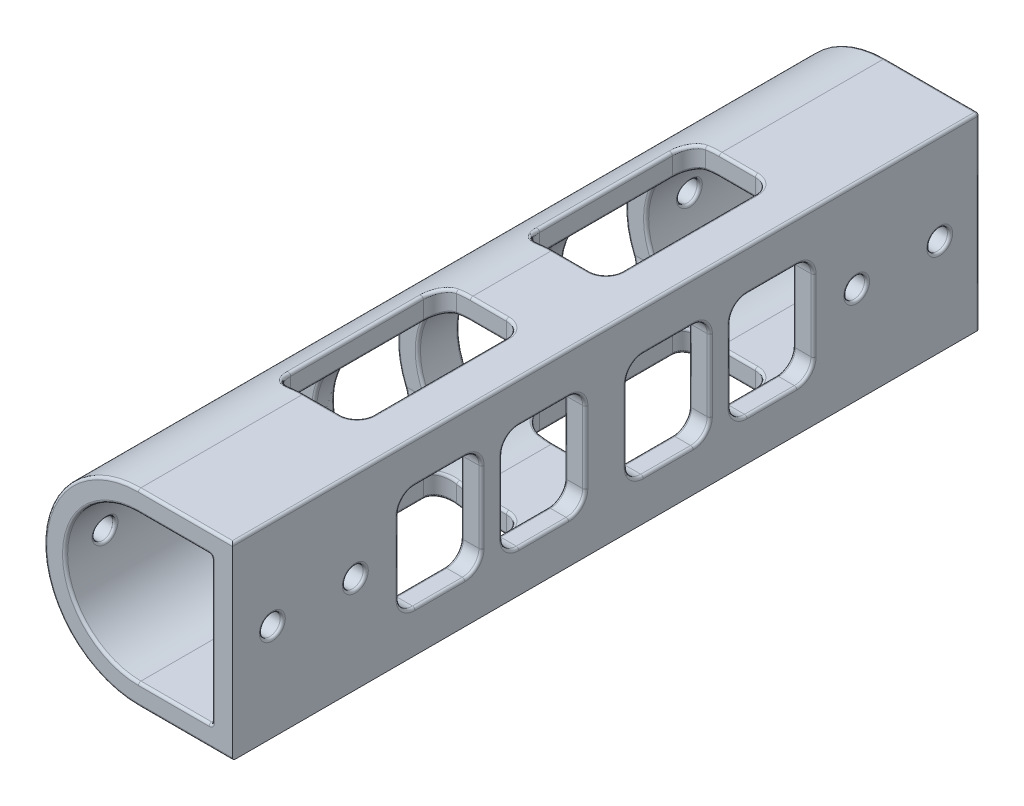
from build123d import *

# Parameters (mm, degrees)
BOSS_EXTRUDE1_DEPTH     = 114.3
CUT_EXTRUDE1_DEPTH      = 25.4
CUT_EXTRUDE1_DEPTH_BACK = 25.4
CUT_EXTRUDE2_DEPTH      = 25.4
CUT_EXTRUDE2_DEPTH_BACK = 25.4
SKETCH7_R               = 1.5875
CUT_EXTRUDE3_DEPTH      = 25.4
CUT_EXTRUDE3_DEPTH_BACK = 25.4
FILLET3_R               = 0.396875


with BuildPart() as part:
    # Sketch1 → Boss-Extrude1 (new body)
    with BuildSketch(Plane.XY):
        with BuildLine():
            Line((0, 10.804196024), (0, 13.979196024))
            ThreePointArc((0, 13.979196024), (-14.39545, -0.416253976), (0, -14.811703976))
            Line((0, -14.811703976), (0, -11.636703976))
            ThreePointArc((0, -11.636703976), (-11.22045, -0.416253976), (0, 10.804196024))
        make_face()
        Polygon((14.39545, 13.979196024), (0, 13.979196024), (0, 10.804196024), (11.22045, 10.804196024), (11.22045, -11.636703976), (0, -11.636703976), (0, -14.811703976), (14.39545, -14.811703976), align=None)
    extrude(amount=BOSS_EXTRUDE1_DEPTH)

    # Sketch3 → Cut-Extrude1 (cut, two sides)
    with BuildSketch(Plane(origin=(0, 0, 0), x_dir=(0, 0, -1), z_dir=(1, 0, 0))) as cut_extrude1_sk:
        with BuildLine():
            Line((-86.36, -8.461703976), (-78.74, -8.461703976))
            ThreePointArc((-78.74, -8.461703976), (-76.943948776, -7.7177552), (-76.2, -5.921703976))
            Line((-76.2, -5.921703976), (-76.2, 5.089196024))
            ThreePointArc((-76.2, 5.089196024), (-76.943948776, 6.885247248), (-78.74, 7.629196024))
            Line((-78.74, 7.629196024), (-86.36, 7.629196024))
            ThreePointArc((-86.36, 7.629196024), (-88.156051224, 6.885247248), (-88.9, 5.089196024))
            Line((-88.9, 5.089196024), (-88.9, -5.921703976))
            ThreePointArc((-88.9, -5.921703976), (-88.156051224, -7.7177552), (-86.36, -8.461703976))
        make_face()
        with BuildLine():
            Line((-70.485, -8.461703976), (-62.865, -8.461703976))
            ThreePointArc((-62.865, -8.461703976), (-61.068948776, -7.7177552), (-60.325, -5.921703976))
            Line((-60.325, -5.921703976), (-60.325, 5.089196024))
            ThreePointArc((-60.325, 5.089196024), (-61.068948776, 6.885247248), (-62.865, 7.629196024))
            Line((-62.865, 7.629196024), (-70.485, 7.629196024))
            ThreePointArc((-70.485, 7.629196024), (-72.281051224, 6.885247248), (-73.025, 5.089196024))
            Line((-73.025, 5.089196024), (-73.025, -5.921703976))
            ThreePointArc((-73.025, -5.921703976), (-72.281051224, -7.7177552), (-70.485, -8.461703976))
        make_face()
        with BuildLine():
            Line((-35.56, -8.461703976), (-27.94, -8.461703976))
            ThreePointArc((-27.94, -8.461703976), (-26.143948776, -7.7177552), (-25.4, -5.921703976))
            Line((-25.4, -5.921703976), (-25.4, 5.089196024))
            ThreePointArc((-25.4, 5.089196024), (-26.143948776, 6.885247248), (-27.94, 7.629196024))
            Line((-27.94, 7.629196024), (-35.56, 7.629196024))
            ThreePointArc((-35.56, 7.629196024), (-37.356051224, 6.885247248), (-38.1, 5.089196024))
            Line((-38.1, 5.089196024), (-38.1, -5.921703976))
            ThreePointArc((-38.1, -5.921703976), (-37.356051224, -7.7177552), (-35.56, -8.461703976))
        make_face()
        with BuildLine():
            Line((-51.435, -8.461703976), (-43.815, -8.461703976))
            ThreePointArc((-43.815, -8.461703976), (-42.018948776, -7.7177552), (-41.275, -5.921703976))
            Line((-41.275, -5.921703976), (-41.275, 5.089196024))
            ThreePointArc((-41.275, 5.089196024), (-42.018948776, 6.885247248), (-43.815, 7.629196024))
            Line((-43.815, 7.629196024), (-51.435, 7.629196024))
            ThreePointArc((-51.435, 7.629196024), (-53.231051224, 6.885247248), (-53.975, 5.089196024))
            Line((-53.975, 5.089196024), (-53.975, -5.921703976))
            ThreePointArc((-53.975, -5.921703976), (-53.231051224, -7.7177552), (-51.435, -8.461703976))
        make_face()
    extrude(amount=CUT_EXTRUDE1_DEPTH, mode=Mode.SUBTRACT)
    extrude(cut_extrude1_sk.sketch, amount=-CUT_EXTRUDE1_DEPTH_BACK, mode=Mode.SUBTRACT)

    # Sketch6 → Cut-Extrude2 (cut, two sides)
    with BuildSketch(Plane(origin=(0, 0, 0), x_dir=(1, 0, 0), z_dir=(0, 1, 0))) as cut_extrude2_sk:
        with BuildLine():
            Line((-2.11455, -25.4), (5.50545, -25.4))
            ThreePointArc((5.50545, -25.4), (7.301501224, -26.143948776), (8.04545, -27.94))
            Line((8.04545, -27.94), (8.04545, -48.26))
            ThreePointArc((8.04545, -48.26), (7.301501224, -50.056051224), (5.50545, -50.8))
            Line((5.50545, -50.8), (-2.11455, -50.8))
            ThreePointArc((-2.11455, -50.8), (-3.910601224, -50.056051224), (-4.65455, -48.26))
            Line((-4.65455, -48.26), (-4.65455, -27.94))
            ThreePointArc((-4.65455, -27.94), (-3.910601224, -26.143948776), (-2.11455, -25.4))
        make_face()
        with BuildLine():
            Line((5.50545, -88.9), (-2.11455, -88.9))
            ThreePointArc((-2.11455, -88.9), (-3.910601224, -88.156051224), (-4.65455, -86.36))
            Line((-4.65455, -86.36), (-4.65455, -66.04))
            ThreePointArc((-4.65455, -66.04), (-3.910601224, -64.243948776), (-2.11455, -63.5))
            Line((-2.11455, -63.5), (5.50545, -63.5))
            ThreePointArc((5.50545, -63.5), (7.301501224, -64.243948776), (8.04545, -66.04))
            Line((8.04545, -66.04), (8.04545, -86.36))
            ThreePointArc((8.04545, -86.36), (7.301501224, -88.156051224), (5.50545, -88.9))
        make_face()
    extrude(amount=CUT_EXTRUDE2_DEPTH, mode=Mode.SUBTRACT)
    extrude(cut_extrude2_sk.sketch, amount=-CUT_EXTRUDE2_DEPTH_BACK, mode=Mode.SUBTRACT)

    # Sketch7 → Cut-Extrude3 (cut, two sides)
    with BuildSketch(Plane(origin=(0, 0, 0), x_dir=(0, 0, -1), z_dir=(1, 0, 0))) as cut_extrude3_sk:
        with Locations((-108.204, 0)):
            Circle(SKETCH7_R)
        with Locations((-95.504, 0)):
            Circle(SKETCH7_R)
        with Locations((-18.796, 0)):
            Circle(SKETCH7_R)
        with Locations((-6.096, 0)):
            Circle(SKETCH7_R)
    extrude(amount=CUT_EXTRUDE3_DEPTH, mode=Mode.SUBTRACT)
    extrude(cut_extrude3_sk.sketch, amount=-CUT_EXTRUDE3_DEPTH_BACK, mode=Mode.SUBTRACT)

    # Fillet3
    fillet3_edges = [part.edges().sort_by_distance(p)[0] for p in [
        (14.39545, -0.416253976, 0),
        (-12.43015713, 6.844611983, 41.979212753),
        (-8.576465417, 6.818574243, 41.954663724),
        (-11.937324449, 7.629196024, 47.625),
        (7.197725, -14.811703976, 0),
        (-7.821076173, 7.629196024, 47.625),
        (-14.39545, -0.416253976, 53.975),
        (-11.22045, -0.416253976, 53.975),
        (-14.39545, -0.416253976, 53.975),
        (-11.22045, -0.416253976, 53.975),
        (-14.39545, -0.416253976, 53.975),
        (-8.576465411, -7.651082181, 53.295336268),
        (-11.937324449, -8.461703976, 47.625),
        (-7.821076173, -8.461703976, 47.625),
        (-12.43015713, -7.677119935, 41.979212754),
        (-8.576465424, -7.651082189, 41.954663732),
        (-14.39545, -0.416253976, 41.275),
        (-11.22045, -0.416253976, 41.275),
        (11.22045, 6.885247248, 42.018948776),
        (5.610225, 10.804196024, 114.3),
        (-14.39545, -0.416253976, 0),
        (11.22045, 7.629196024, 47.625),
        (11.22045, 6.885247248, 53.231051224),
        (11.22045, -0.416253976, 53.975),
        (11.22045, -7.7177552, 53.231051224),
        (11.22045, -8.461703976, 47.625),
        (11.22045, -7.7177552, 42.018948776),
        (11.22045, -0.416253976, 41.275),
        (7.197725, 13.979196024, 0),
        (5.610225, -11.636703976, 0),
        (11.22045, -0.416253976, 0),
        (5.610225, 10.804196024, 0),
        (-12.43015711, -7.677119957, 61.029212717),
        (-8.576465424, -7.651082188, 61.004663732),
        (-14.39545, -0.416253976, 60.325),
        (-11.22045, -0.416253976, 60.325),
        (-12.43015713, 6.844611983, 61.029212753),
        (-8.576465417, 6.818574243, 61.004663724),
        (-11.937324449, 7.629196024, 66.675),
        (-7.821076173, 7.629196024, 66.675),
        (-12.43015711, 6.844612005, 72.320787283),
        (-11.22045, -0.416253976, 0),
        (-11.22045, -0.416253976, 73.025),
        (-14.39545, -0.416253976, 73.025),
        (-11.22045, -0.416253976, 73.025),
        (-14.39545, -0.416253976, 73.025),
        (-8.576465417, -7.651082195, 72.345336276),
        (-11.937324449, -8.461703976, 66.675),
        (-7.821076173, -8.461703976, 66.675),
        (11.22045, -7.7177552, 61.068948776),
        (11.22045, -0.416253976, 60.325),
        (11.22045, 6.885247248, 61.068948776),
        (11.22045, 7.629196024, 66.675),
        (11.22045, 6.885247248, 72.281051224),
        (11.22045, -0.416253976, 73.025),
        (11.22045, -7.7177552, 72.281051224),
        (11.22045, -8.461703976, 66.675),
        (-14.39545, -0.416253976, 38.1),
        (11.22045, -0.416253976, 114.3),
        (-11.22045, -0.416253976, 38.1),
        (-14.39545, -0.416253976, 38.1),
        (14.39545, 13.979196024, 57.15),
        (-11.22045, -0.416253976, 38.1),
        (-12.43015713, -7.677119934, 37.395787247),
        (-8.576465417, -7.651082195, 37.420336276),
        (-11.937324449, -8.461703976, 31.75),
        (-7.821076173, -8.461703976, 31.75),
        (-12.43015713, -7.677119935, 26.104212755),
        (-8.576465425, -7.651082188, 26.079663731),
        (-14.39545, -0.416253976, 25.4),
        (-11.22045, -0.416253976, 25.4),
        (-12.430157127, 6.844611984, 26.104212753),
        (-8.576465411, 6.818574229, 26.079663732),
        (11.22045, -11.636703976, 57.15),
        (-11.937324449, 7.629196024, 31.75),
        (-7.821076173, 7.629196024, 31.75),
        (11.22045, 6.885247248, 37.356051224),
        (11.22045, 10.804196024, 57.15),
        (11.22045, -0.416253976, 38.1),
        (11.22045, -7.7177552, 37.356051224),
        (11.22045, -8.461703976, 31.75),
        (11.22045, -7.7177552, 26.143948776),
        (11.22045, -0.416253976, 25.4),
        (11.22045, 6.885247248, 26.143948776),
        (11.22045, 7.629196024, 31.75),
        (5.610225, -11.636703976, 114.3),
        (14.39545, 7.629196024, 31.75),
        (7.197725, 13.979196024, 114.3),
        (14.39545, 6.885247248, 26.143948776),
        (14.39545, -0.416253976, 25.4),
        (14.39545, -7.7177552, 26.143948776),
        (14.39545, -8.461703976, 31.75),
        (14.39545, -7.7177552, 37.356051224),
        (2.752725, -11.636703976, 25.4),
        (7.301501224, -11.636703976, 26.143948776),
        (8.04545, -11.636703976, 38.1),
        (7.301501224, -11.636703976, 50.056051224),
        (2.752725, -11.636703976, 50.8),
        (2.752725, -11.636703976, 63.5),
        (7.301501224, -11.636703976, 64.243948776),
        (8.04545, -11.636703976, 76.2),
        (14.39545, -0.416253976, 38.1),
        (7.301501224, -11.636703976, 88.156051224),
        (2.752725, -11.636703976, 88.9),
        (14.39545, 6.885247248, 37.356051224),
        (14.39545, -8.461703976, 66.675),
        (-4.65455, 9.79323487, 38.1),
        (-3.899161195, 10.10491703, 26.132581168),
        (-3.899161208, 10.104917066, 50.067418831),
        (14.39545, -7.7177552, 72.281051224),
        (-4.65455, -10.625742822, 38.1),
        (-3.899161195, -10.937424982, 26.132581168),
        (-3.899161208, -10.937425018, 50.067418831),
        (-4.65455, 9.79323487, 76.2),
        (-3.899161208, 10.104917066, 64.232581168),
        (-3.899161208, 10.104917066, 88.167418831),
        (14.39545, -0.416253976, 73.025),
        (-4.65455, -10.625742822, 76.2),
        (-3.899161208, -10.937425017, 64.232581168),
        (-3.899161208, -10.937425018, 88.167418831),
        (14.39545, 6.885247248, 72.281051224),
        (14.39545, 7.629196024, 66.675),
        (-3.903568139, 13.439832647, 88.163056876),
        (-3.903568139, -14.272340598, 88.163056876),
        (-3.903568142, 13.439832642, 64.236943116),
        (-3.903568142, -14.272340594, 64.236943116),
        (-4.65455, -14.038447081, 76.2),
        (14.39545, 6.885247248, 61.068948776),
        (-4.65455, 13.205939129, 76.2),
        (2.752725, 10.804196024, 88.9),
        (2.752725, 13.979196024, 88.9),
        (-1.060153831, 13.940105401, 88.9),
        (2.752725, -14.811703976, 88.9),
        (-1.060153831, -14.772613353, 88.9),
        (7.301501224, -14.811703976, 88.156051224),
        (8.04545, -14.811703976, 76.2),
        (7.301501224, -14.811703976, 64.243948776),
        (14.39545, -0.416253976, 60.325),
        (2.752725, 13.979196024, 63.5),
        (2.752725, 10.804196024, 63.5),
        (-1.060153831, 13.940105401, 63.5),
        (-1.060153831, -14.772613353, 63.5),
        (2.752725, -14.811703976, 63.5),
        (-14.39545, -0.416253976, 114.3),
        (-1.062043173, 10.753820442, 88.9),
        (-1.062043173, -11.586328394, 88.9),
        (7.301501224, 13.979196024, 88.156051224),
        (7.301501224, 10.804196024, 88.156051224),
        (8.04545, 13.979196024, 76.2),
        (8.04545, 10.804196024, 76.2),
        (7.301501224, 13.979196024, 64.243948776),
        (7.301501224, 10.804196024, 64.243948776),
        (-1.062043173, 10.753820442, 63.5),
        (14.39545, -7.7177552, 61.068948776),
        (-1.062043173, -11.586328394, 63.5),
        (14.39545, -0.416253976, 41.275),
        (14.39545, -7.7177552, 42.018948776),
        (14.39545, -8.461703976, 47.625),
        (14.39545, -7.7177552, 53.231051224),
        (-3.903568139, 13.439832647, 50.063056876),
        (-3.903568139, -14.272340598, 50.063056876),
        (14.39545, -0.416253976, 53.975),
        (-3.903568138, 13.439832647, 26.136943123),
        (-3.903568138, -14.272340598, 26.136943123),
        (-4.65455, -14.038447081, 38.1),
        (-4.65455, 13.205939129, 38.1),
        (2.752725, 10.804196024, 50.8),
        (2.752725, 13.979196024, 50.8),
        (-1.060153831, 13.940105401, 50.8),
        (2.752725, -14.811703976, 50.8),
        (-1.060153831, -14.772613353, 50.8),
        (7.301501224, -14.811703976, 50.056051224),
        (14.39545, 6.885247248, 53.231051224),
        (8.04545, -14.811703976, 38.1),
        (7.301501224, -14.811703976, 26.143948776),
        (2.752725, 13.979196024, 25.4),
        (2.752725, 10.804196024, 25.4),
        (-1.060153831, 13.940105401, 25.4),
        (-1.060153831, -14.772613353, 25.4),
        (2.752725, -14.811703976, 25.4),
        (-1.062043173, 10.753820442, 50.8),
        (-1.062043173, -11.586328394, 50.8),
        (14.39545, 7.629196024, 47.625),
        (7.301501224, 13.979196024, 50.056051224),
        (7.301501224, 10.804196024, 50.056051224),
        (8.04545, 13.979196024, 38.1),
        (8.04545, 10.804196024, 38.1),
        (7.301501224, 13.979196024, 26.143948776),
        (7.301501224, 10.804196024, 26.143948776),
        (-1.062043173, 10.753820442, 25.4),
        (-1.062043173, -11.586328394, 25.4),
        (14.39545, 6.885247248, 42.018948776),
        (14.39545, -0.416253976, 76.2),
        (14.39545, -7.7177552, 76.943948776),
        (14.39545, -8.461703976, 82.55),
        (7.197725, -14.811703976, 114.3),
        (14.39545, -7.7177552, 88.156051224),
        (14.39545, -0.416253976, 88.9),
        (14.39545, 6.885247248, 88.156051224),
        (14.39545, 7.629196024, 82.55),
        (14.39545, 6.885247248, 76.943948776),
        (-11.212515297, 0.005645207, 7.683489969),
        (-14.38933166, 0.003407862, 7.68349635),
        (11.22045, 0, 7.6835),
        (14.39545, 0, 7.6835),
        (-11.212515297, 0.005645207, 20.383489969),
        (-14.38933166, 0.003407862, 20.38349635),
        (11.22045, 0, 20.3835),
        (14.39545, 0, 20.3835),
        (-14.38933166, 0.003407862, 97.09149635),
        (-11.212515297, 0.005645207, 97.091489969),
        (11.22045, 0, 97.0915),
        (14.39545, 0, 97.0915),
        (-14.38933166, 0.003407862, 109.79149635),
        (-11.212515297, 0.005645207, 109.791489969),
        (11.22045, 0, 109.7915),
        (14.39545, 0, 109.7915),
        (-11.22045, -0.416253976, 114.3),
        (-12.43015713, 6.844611983, 76.904212753),
        (-8.576465417, 6.818574243, 76.879663724),
        (-11.937324449, 7.629196024, 82.55),
        (-7.821076173, 7.629196024, 82.55),
        (-12.43015711, 6.844612005, 88.195787283),
        (-8.576465412, 6.818574228, 88.220336269),
        (-14.39545, -0.416253976, 88.9),
        (-11.22045, -0.416253976, 88.9),
        (-14.39545, -0.416253976, 88.9),
        (-11.22045, -0.416253976, 88.9),
        (-11.937324449, -8.461703976, 82.55),
        (-7.821076173, -8.461703976, 82.55),
        (-12.43015713, -7.677119935, 76.904212754),
        (-8.576465424, -7.651082188, 76.879663732),
        (-14.39545, -0.416253976, 76.2),
        (-11.22045, -0.416253976, 76.2),
        (11.22045, 6.885247248, 76.943948776),
        (11.22045, 7.629196024, 82.55),
        (11.22045, 6.885247248, 88.156051224),
        (11.22045, -0.416253976, 88.9),
        (11.22045, -7.7177552, 88.156051224),
        (11.22045, -8.461703976, 82.55),
        (11.22045, -7.7177552, 76.943948776),
        (11.22045, -0.416253976, 76.2),
    ]]
    fillet(fillet3_edges, radius=FILLET3_R)


solid = part.part
